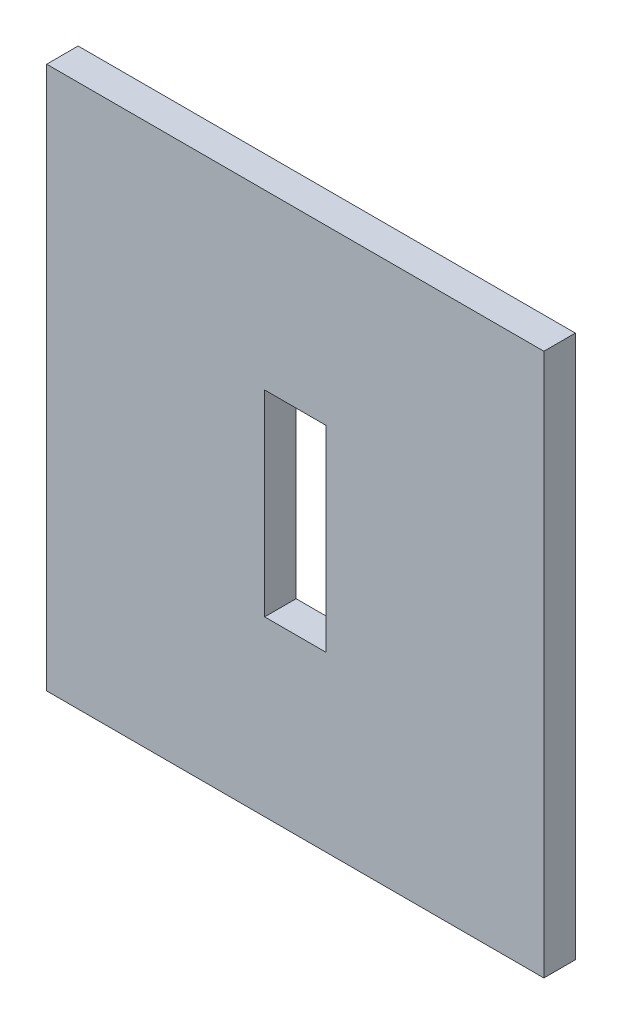
from build123d import *

# Parameters (mm, degrees)
SKETCH1_W           = 50.17
SKETCH1_H           = 54.77
BOSS_EXTRUDE1_DEPTH = 3.175
SKETCH3_W           = 6.18
SKETCH3_H           = 19.83
CUT_EXTRUDE1_DEPTH  = 38.27299391


with BuildPart() as part:
    # Sketch1 → Boss-Extrude1 (new body)
    with BuildSketch(Plane.XY):
        Rectangle(SKETCH1_W, SKETCH1_H)
    extrude(amount=BOSS_EXTRUDE1_DEPTH)

    # Sketch3 → Cut-Extrude1 (cut, through all)
    with BuildSketch(Plane.XY.offset(3.175)):
        Rectangle(SKETCH3_W, SKETCH3_H)
    extrude(amount=-CUT_EXTRUDE1_DEPTH, mode=Mode.SUBTRACT)


solid = part.part
